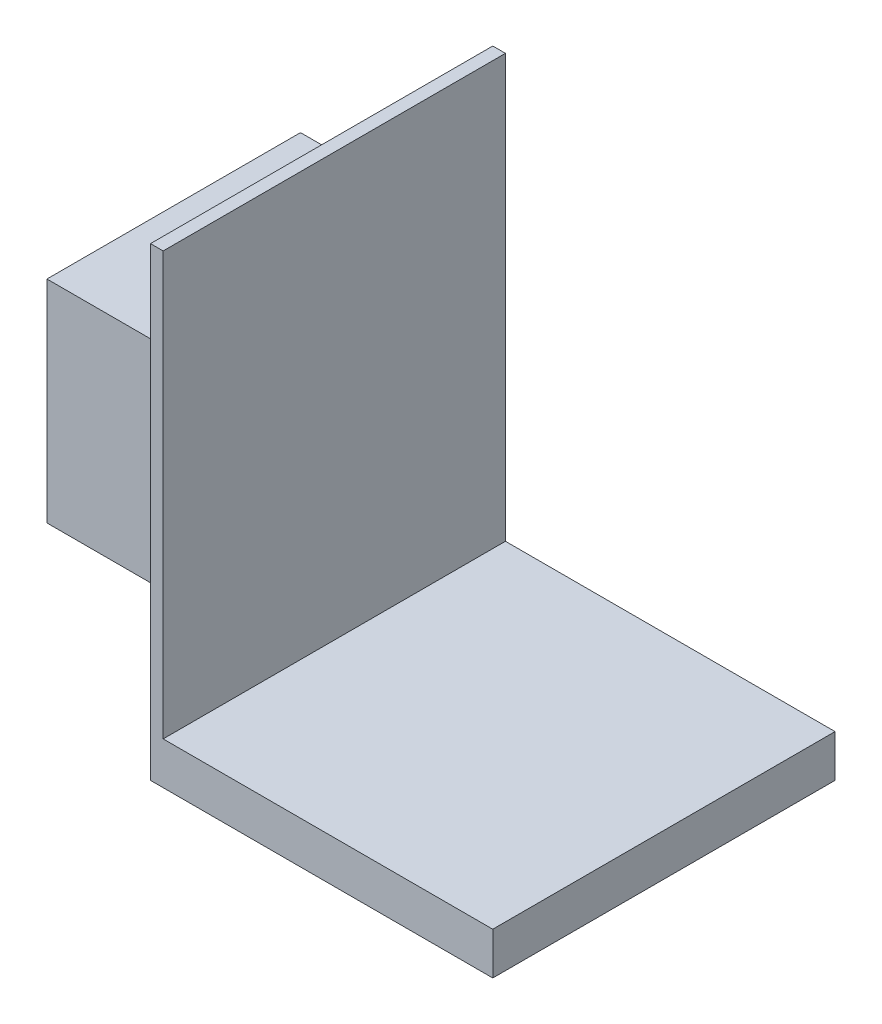
from build123d import *

# Parameters (mm, degrees)
SKETCH1_W           = 81
SKETCH1_H           = 81
BOSS_EXTRUDE1_DEPTH = 10
BOSS_EXTRUDE2_START = 10
SKETCH2_W           = 3
SKETCH2_H           = 81
BOSS_EXTRUDE2_DEPTH = 100
SKETCH3_W           = 60
SKETCH3_H           = 50
BOSS_EXTRUDE3_DEPTH = 35
CUT_EXTRUDE1_REACH  = 82
SKETCH4_R           = 5
CUT_EXTRUDE4_START  = -20
CUT_EXTRUDE4_DEPTH  = 20


with BuildPart() as part:
    # Sketch1 → Boss-Extrude1 (new body)
    with BuildSketch(Plane(origin=(0, 0, 0), x_dir=(1, 0, 0), z_dir=(0, 1, 0))):
        Rectangle(SKETCH1_W, SKETCH1_H)
    extrude(amount=BOSS_EXTRUDE1_DEPTH)

    # Sketch2 → Boss-Extrude2 (add)
    with BuildSketch(Plane(origin=(0, 0, 0), x_dir=(1, 0, 0), z_dir=(0, 1, 0)).offset(BOSS_EXTRUDE2_START)):
        with Locations((-39, 0)):
            Rectangle(SKETCH2_W, SKETCH2_H)
    extrude(amount=BOSS_EXTRUDE2_DEPTH)

    # Sketch3 → Boss-Extrude3 (add)
    with BuildSketch(Plane.ZY.offset(40.5)):
        with Locations((0, 55)):
            Rectangle(SKETCH3_W, SKETCH3_H)
    extrude(amount=BOSS_EXTRUDE3_DEPTH)

    # Sketch4 → Cut-Extrude1 (cut, up to next)
    with BuildSketch(Plane(origin=(0, 80, 0), x_dir=(1, 0, 0), z_dir=(0, 1, 0)), mode=Mode.PRIVATE) as cut_extrude1_sk1:
        with Locations((-55.5, 15)):
            Circle(SKETCH4_R)
    cut_extrude1_tool1 = extrude(cut_extrude1_sk1.sketch, amount=-CUT_EXTRUDE1_REACH, mode=Mode.PRIVATE) & part.part
    add(cut_extrude1_tool1.solids().sort_by_distance((-55.5, 80, -15))[0], mode=Mode.SUBTRACT)
    # Sketch4 → Cut-Extrude1 (cut, up to next)
    with BuildSketch(Plane(origin=(0, 80, 0), x_dir=(1, 0, 0), z_dir=(0, 1, 0)), mode=Mode.PRIVATE) as cut_extrude1_sk2:
        with Locations((-55.5, -15)):
            Circle(SKETCH4_R)
    cut_extrude1_tool2 = extrude(cut_extrude1_sk2.sketch, amount=-CUT_EXTRUDE1_REACH, mode=Mode.PRIVATE) & part.part
    add(cut_extrude1_tool2.solids().sort_by_distance((-55.5, 80, 15))[0], mode=Mode.SUBTRACT)

    # Sketch5 → Cut-Extrude4 (cut)
    with BuildSketch(Plane.XY.offset(30).offset(CUT_EXTRUDE4_START)):
        Polygon((-75.5, 75), (-75.5, 70), (-65.5, 70), (-65.5, 80), (-70.5, 80), (-70.5, 75), align=None)
        Polygon((-65.5, 30), (-65.5, 40), (-75.5, 40), (-75.5, 35), (-70.5, 35), (-70.5, 30), align=None)
    extrude(amount=-CUT_EXTRUDE4_DEPTH, mode=Mode.SUBTRACT)


solid = part.part
